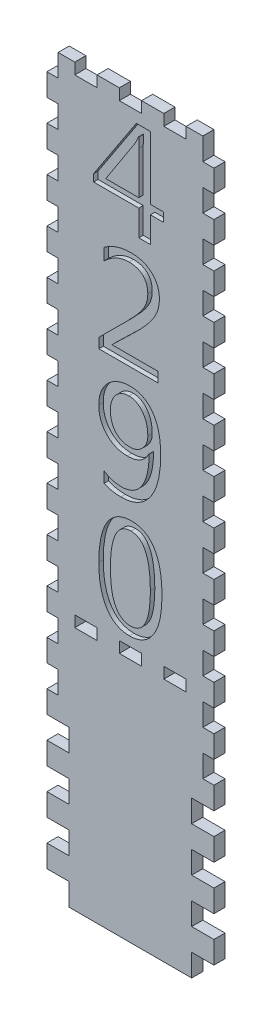
from build123d import *

# Parameters (mm, degrees)
SKETCH2_W           = 95.25
SKETCH2_H           = 419.1
BOSS_EXTRUDE1_DEPTH = 6.35
SKETCH3_W           = 6.35
SKETCH3_H           = 12.7
CUT_EXTRUDE1_DEPTH  = 7.35
LPATTERN1_COUNT     = 17
LPATTERN1_PITCH     = 25.4
SKETCH4_W           = 12.7
SKETCH4_H           = 6.35
CUT_EXTRUDE2_DEPTH  = 7.35
SKETCH5_W           = 6.35
SKETCH5_H           = 12.7
CUT_EXTRUDE3_DEPTH  = 7.35
LPATTERN2_COUNT     = 4
LPATTERN2_PITCH     = 25.4
SKETCH6_W           = 12.7
SKETCH6_H           = 6.35
CUT_EXTRUDE4_DEPTH  = 7.35
LPATTERN3_COUNT     = 2
LPATTERN3_PITCH     = 25.4
LPATTERN3_COL_COUNT = 2
LPATTERN3_COL_PITCH = 25.4
CUT_EXTRUDE5_DEPTH  = 2.54


with BuildPart() as part:
    # Sketch2 → Boss-Extrude1 (new body)
    with BuildSketch(Plane.XY):
        with Locations((47.625, 209.55)):
            Rectangle(SKETCH2_W, SKETCH2_H)
    extrude(amount=BOSS_EXTRUDE1_DEPTH)

    # Sketch3 → Cut-Extrude1 (cut, through all)
    with BuildSketch(Plane.XY.offset(6.35)):
        with Locations((3.175, 6.35)):
            Rectangle(SKETCH3_W, SKETCH3_H)
        with Locations((92.075, 6.35)):
            Rectangle(SKETCH3_W, SKETCH3_H)
    cut_extrude1 = extrude(amount=-CUT_EXTRUDE1_DEPTH, mode=Mode.SUBTRACT)

    # LPattern1: Cut-Extrude1 ×17
    with Locations(*[(0, i * LPATTERN1_PITCH, 0) for i in range(1, LPATTERN1_COUNT)]):
        add(cut_extrude1, mode=Mode.SUBTRACT)

    # Sketch4 → Cut-Extrude2 (cut, through all)
    with BuildSketch(Plane.XY.offset(6.35)):
        with Locations((47.625, 415.925)):
            Rectangle(SKETCH4_W, SKETCH4_H)
        with Locations((22.225, 415.925)):
            Rectangle(SKETCH4_W, SKETCH4_H)
        with Locations((73.025, 415.925)):
            Rectangle(SKETCH4_W, SKETCH4_H)
    extrude(amount=-CUT_EXTRUDE2_DEPTH, mode=Mode.SUBTRACT)

    # Sketch5 → Cut-Extrude3 (cut, through all)
    with BuildSketch(Plane.XY.offset(6.35)):
        with Locations((9.525, 6.35)):
            Rectangle(SKETCH5_W, SKETCH5_H)
        with Locations((85.725, 6.35)):
            Rectangle(SKETCH5_W, SKETCH5_H)
    cut_extrude3 = extrude(amount=-CUT_EXTRUDE3_DEPTH, mode=Mode.SUBTRACT)

    # LPattern2: Cut-Extrude3 ×4
    with Locations(*[(0, i * LPATTERN2_PITCH, 0) for i in range(1, LPATTERN2_COUNT)]):
        add(cut_extrude3, mode=Mode.SUBTRACT)

    # Sketch6 → Cut-Extrude4 (cut, through all)
    with BuildSketch(Plane.XY.offset(6.35)):
        with Locations((47.625, 142.875)):
            Rectangle(SKETCH6_W, SKETCH6_H)
    cut_extrude4 = extrude(amount=-CUT_EXTRUDE4_DEPTH, mode=Mode.SUBTRACT)

    # LPattern3: Cut-Extrude4 ×2
    with Locations(*[(i * LPATTERN3_PITCH, 0, 0) for i in range(1, LPATTERN3_COUNT)]):
        add(cut_extrude4, mode=Mode.SUBTRACT)

    # LPattern3 col: Cut-Extrude4 ×2
    with Locations(*[(-i * LPATTERN3_COL_PITCH, 0, 0) for i in range(1, LPATTERN3_COL_COUNT)]):
        add(cut_extrude4, mode=Mode.SUBTRACT)

    # Sketch7 → Cut-Extrude5 (cut)
    with BuildSketch(Plane.XY.offset(6.35)):
        Polygon((66.347473684, 365.225263158), (58.994842105, 365.225263158), (58.994842105, 350.52), (52.377473684, 350.52), (52.377473684, 365.225263158), (26.643263158, 365.225263158), (26.643263158, 369.361118421), (50.987366776, 406.4), (58.994842105, 406.4), (58.994842105, 370.372105263), (66.347473684, 370.372105263), align=None)
        with BuildLine():
            Line((52.377473684, 370.372105263), (52.377473684, 394.704720395))
            add(Edge.make_bspline(
                [(52.377473684, 394.704720395), (52.388280309, 395.620092385), (52.411121203, 397.554823508), (52.494422978, 399.487912378), (52.5383125, 400.50640625)],
                knots=[0, 0, 0, 0, 0.002746133, 0.005804229, 0.005804229, 0.005804229, 0.005804229], degree=3))
            Line((52.5383125, 400.50640625), (52.377473684, 400.50640625))
            add(Edge.make_bspline(
                [(52.377473684, 400.50640625), (52.268298001, 400.23754225), (52.024369803, 399.636826877), (51.566852144, 398.646813106), (50.970030559, 397.480008962), (50.525074381, 396.638044684), (50.286569079, 396.186735197)],
                knots=[0, 0, 0, 0, 0.000870476, 0.001944879, 0.003270444, 0.004801821, 0.004801821, 0.004801821, 0.004801821], degree=3))
            Line((50.286569079, 396.186735197), (33.54784375, 370.372105263))
            Line((33.54784375, 370.372105263), (52.377473684, 370.372105263))
        make_face(mode=Mode.SUBTRACT)
        with BuildLine():
            Line((63.406421053, 284.346315789), (29.584315789, 284.346315789))
            Line((29.584315789, 284.346315789), (29.584315789, 289.998651316))
            Line((29.584315789, 289.998651316), (45.920944079, 306.277837171))
            add(Edge.make_bspline(
                [(45.920944079, 306.277837171), (46.424180259, 306.781776596), (47.403956985, 307.762922505), (48.802074245, 309.214703689), (50.083014798, 310.611140989), (51.251077352, 311.943602605), (52.323826912, 313.198147905), (53.264671489, 314.400862364), (54.110599327, 315.523432912), (55.067027443, 316.929922001), (56.059985441, 318.682722154), (56.911097233, 320.877906643), (57.419517358, 323.150388241), (57.489331051, 324.69139001), (57.524315789, 325.463610197)],
                knots=[0, 0, 0, 0, 0.002136519, 0.0041597, 0.006046122, 0.007820712, 0.009475573, 0.010997092, 0.012400993, 0.013691493, 0.016098407, 0.018426066, 0.020731362, 0.023046969, 0.023046969, 0.023046969, 0.023046969], degree=3))
            add(Edge.make_bspline(
                [(57.524315789, 325.463610197), (57.514635558, 325.862149993), (57.495690632, 326.642121662), (57.37335109, 327.777250653), (57.151643335, 328.840992955), (56.856810686, 329.836501691), (56.464816334, 330.762107925), (55.978947694, 331.615158354), (55.413223909, 332.401273896), (54.768993183, 333.117412387), (54.039830798, 333.753755675), (53.231194025, 334.303309313), (52.353349238, 334.782423002), (51.393154072, 335.154728995), (50.368207585, 335.458082751), (49.266601956, 335.659146269), (48.095317636, 335.787752189), (47.288431348, 335.805587237), (46.874488487, 335.814736842)],
                knots=[0, 0, 0, 0, 0.001195686, 0.002340045, 0.003419291, 0.004451466, 0.005450106, 0.00642764, 0.007390551, 0.008350372, 0.009311156, 0.010286257, 0.011278333, 0.012304481, 0.013369694, 0.014480518, 0.015659138, 0.016900745, 0.016900745, 0.016900745, 0.016900745], degree=3))
            add(Edge.make_bspline(
                [(46.874488487, 335.814736842), (46.25286361, 335.79464315), (45.005788435, 335.75433211), (43.151945351, 335.432571391), (41.319800132, 334.910310756), (39.508805702, 334.178091001), (37.713595454, 333.247243103), (35.949789473, 332.092774033), (34.195710705, 330.751210173), (33.09149022, 329.724005205), (32.525368421, 329.197368421)],
                knots=[0, 0, 0, 0, 0.001864005, 0.00373948, 0.005626847, 0.007570338, 0.009589731, 0.011683348, 0.013887013, 0.016205439, 0.016205439, 0.016205439, 0.016205439], degree=3))
            Line((32.525368421, 329.197368421), (32.525368421, 335.872179276))
            add(Edge.make_bspline(
                [(32.525368421, 335.872179276), (33.081392691, 336.280781464), (34.185531177, 337.092173026), (35.952907748, 338.119204914), (37.777449228, 339.005833765), (39.677783191, 339.708952614), (41.639874019, 340.286883805), (43.677191261, 340.662705656), (45.776598564, 340.918351154), (47.199206981, 340.947042896), (47.919940789, 340.961578947)],
                knots=[0, 0, 0, 0, 0.002068725, 0.004108021, 0.006122277, 0.008147284, 0.010179837, 0.012250476, 0.014355253, 0.016516585, 0.016516585, 0.016516585, 0.016516585], degree=3))
            add(Edge.make_bspline(
                [(47.919940789, 340.961578947), (48.533340814, 340.953587419), (49.729010038, 340.938009943), (51.470941529, 340.728696975), (53.120401315, 340.433474499), (54.662404553, 339.976331525), (56.112970377, 339.421327851), (57.447087516, 338.711885893), (58.692614943, 337.89265137), (59.824127913, 336.942349453), (60.834571124, 335.881587928), (61.72598193, 334.742308658), (62.480063224, 333.514097248), (63.091123142, 332.195217168), (63.562169027, 330.788192145), (63.890647629, 329.2936227), (64.104976112, 327.717709362), (64.129277518, 326.636157461), (64.141684211, 326.083988487)],
                knots=[0, 0, 0, 0, 0.001839055, 0.003584776, 0.005256657, 0.00685999, 0.008402445, 0.009908139, 0.011383414, 0.012867609, 0.014330216, 0.015771094, 0.017199598, 0.018643907, 0.020122534, 0.021641536, 0.023228986, 0.024884763, 0.024884763, 0.024884763, 0.024884763], degree=3))
            add(Edge.make_bspline(
                [(64.141684211, 326.083988487), (64.132428295, 325.639483869), (64.113872596, 324.748367965), (63.976184445, 323.414687035), (63.726945853, 322.093411946), (63.410558875, 320.773553), (62.979788994, 319.467290717), (62.466493615, 318.162491649), (61.834268288, 316.878490523), (61.134460559, 315.572547227), (60.286394085, 314.248619886), (59.30784552, 312.858154214), (58.178086715, 311.388859647), (56.903533298, 309.839799938), (55.473594387, 308.21590248), (53.885244676, 306.524698203), (52.166776858, 304.738642787), (50.948525035, 303.547971807), (50.321034539, 302.9346875)],
                knots=[0, 0, 0, 0, 0.001333457, 0.002673233, 0.004016256, 0.005364869, 0.006741811, 0.008139163, 0.009567621, 0.011032797, 0.012581827, 0.014280648, 0.016132683, 0.018140573, 0.020297749, 0.022622515, 0.025100542, 0.027732634, 0.027732634, 0.027732634, 0.027732634], degree=3))
            Line((50.321034539, 302.9346875), (37.224159539, 290.228421053))
            Line((37.224159539, 290.228421053), (37.224159539, 290.079070724))
            Line((37.224159539, 290.079070724), (63.406421053, 290.079070724))
            Line((63.406421053, 290.079070724), (63.406421053, 284.346315789))
        make_face()
        with BuildLine():
            Line((32.525368421, 219.321480263), (32.525368421, 225.525263158))
            add(Edge.make_bspline(
                [(32.525368421, 225.525263158), (32.912936327, 225.29008708), (33.678389294, 224.825610471), (34.866453366, 224.230549391), (36.068817976, 223.716345854), (37.292372091, 223.309192909), (38.530987956, 222.981113547), (39.783313171, 222.754228425), (41.05410218, 222.61002138), (41.907246616, 222.592850605), (42.336536184, 222.584210526)],
                knots=[0, 0, 0, 0, 0.00135953, 0.002685095, 0.003982429, 0.005279408, 0.006550067, 0.007823218, 0.009094449, 0.01038198, 0.01038198, 0.01038198, 0.01038198], degree=3))
            add(Edge.make_bspline(
                [(42.336536184, 222.584210526), (42.946840108, 222.598946099), (44.144526951, 222.627863823), (45.882181555, 222.940613636), (47.524655753, 223.414924585), (49.048920459, 224.116651516), (50.476758173, 224.994819317), (51.79948828, 226.075064369), (53.003390312, 227.36206971), (54.110582692, 228.828014014), (55.094984841, 230.472709594), (55.950028018, 232.288915017), (56.648828462, 234.272485624), (57.255082891, 236.406860682), (57.708820054, 238.712565964), (58.021142036, 241.180934387), (58.221038608, 243.811666713), (58.246472616, 245.618248963), (58.259578947, 246.549194079)],
                knots=[0, 0, 0, 0, 0.00182898, 0.00358927, 0.005279483, 0.006945274, 0.008606344, 0.010296558, 0.01205193, 0.01388091, 0.015797973, 0.017791979, 0.019892456, 0.022100189, 0.02444339, 0.026934273, 0.029560919, 0.032353472, 0.032353472, 0.032353472, 0.032353472], degree=3))
            add(Edge.make_bspline(
                [(58.259578947, 246.549194079), (58.2327466, 246.543138734), (58.182832194, 246.531874385), (58.133186442, 246.543717455), (58.110228618, 246.549194079)],
                knots=[0, 0, 0, 0, 8.1236e-05, 0.000151118, 0.000151118, 0.000151118, 0.000151118], degree=3))
            add(Edge.make_bspline(
                [(58.110228618, 246.549194079), (57.804701544, 245.987492974), (57.206941762, 244.888532005), (56.053306012, 243.443275545), (54.741629714, 242.217729519), (53.260874947, 241.222266521), (51.624592639, 240.428493463), (49.814001076, 239.882788036), (47.843315767, 239.561468208), (46.477466043, 239.517820388), (45.77159375, 239.495263158)],
                knots=[0, 0, 0, 0, 0.001915238, 0.003747138, 0.005519272, 0.007281361, 0.009079777, 0.0109549, 0.012934257, 0.015051258, 0.015051258, 0.015051258, 0.015051258], degree=3))
            add(Edge.make_bspline(
                [(45.77159375, 239.495263158), (45.192405325, 239.505632938), (44.056016077, 239.525978834), (42.396333729, 239.770661183), (40.809670362, 240.126584475), (39.312631323, 240.665252894), (37.887576693, 241.329674648), (36.547392936, 242.156366028), (35.278357211, 243.119248715), (34.114581442, 244.238569835), (33.044898229, 245.456436135), (32.121934878, 246.78915868), (31.340217275, 248.20704629), (30.691575304, 249.705674722), (30.197631483, 251.293443032), (29.846027329, 252.962755584), (29.618227914, 254.718900922), (29.595785295, 255.919243224), (29.584315789, 256.532689145)],
                knots=[0, 0, 0, 0, 0.00173613, 0.003406353, 0.00502264, 0.006606885, 0.008169193, 0.009731669, 0.011321736, 0.01293884, 0.014567533, 0.016176946, 0.0177916, 0.019417779, 0.021067407, 0.022770883, 0.024530723, 0.026370173, 0.026370173, 0.026370173, 0.026370173], degree=3))
            add(Edge.make_bspline(
                [(29.584315789, 256.532689145), (29.600375888, 257.184335692), (29.631937134, 258.464949062), (29.861617632, 260.338800498), (30.253855131, 262.123737199), (30.803813016, 263.818992286), (31.521181877, 265.422041193), (32.388737239, 266.939756553), (33.411194923, 268.365828642), (34.587533996, 269.683513275), (35.870523495, 270.888619385), (37.274244162, 271.922883666), (38.750262088, 272.817432437), (40.320385368, 273.547436701), (41.985533271, 274.092277085), (43.729880254, 274.498337261), (45.565477077, 274.743900474), (46.820120703, 274.773029407), (47.460401316, 274.787894737)],
                knots=[0, 0, 0, 0, 0.001954698, 0.003841365, 0.005653198, 0.007429758, 0.009178312, 0.010912502, 0.012666031, 0.01443201, 0.016204144, 0.017936621, 0.019652718, 0.02137465, 0.02311848, 0.024899233, 0.026741765, 0.028662027, 0.028662027, 0.028662027, 0.028662027], degree=3))
            add(Edge.make_bspline(
                [(47.460401316, 274.787894737), (48.127912342, 274.768173716), (49.431578674, 274.729658052), (51.332659893, 274.42429614), (53.122665565, 273.925701518), (54.792779881, 273.199345934), (56.356982153, 272.294122164), (57.793392304, 271.159736953), (59.117633164, 269.83159825), (60.327238032, 268.305528756), (61.409192721, 266.589486011), (62.33628842, 264.678686722), (63.131217748, 262.592066789), (63.768214418, 260.314059832), (64.272112041, 257.85720303), (64.619370885, 255.211861634), (64.843521788, 252.389236889), (64.865597758, 250.444244547), (64.876947368, 249.444292763)],
                knots=[0, 0, 0, 0, 0.002001669, 0.003909311, 0.005760384, 0.00756155, 0.009358535, 0.011167196, 0.013035621, 0.014973365, 0.016997329, 0.019109024, 0.021334412, 0.023687309, 0.026197274, 0.028852134, 0.031686719, 0.034686006, 0.034686006, 0.034686006, 0.034686006], degree=3))
            add(Edge.make_bspline(
                [(64.876947368, 249.444292763), (64.861802976, 248.199049441), (64.832356379, 245.777811463), (64.533481599, 242.261288844), (64.088211472, 238.962336071), (63.43558059, 235.880911486), (62.585662748, 233.020785211), (61.572939263, 230.370484241), (60.34373022, 227.954506151), (58.949486364, 225.752769775), (57.374279726, 223.797591852), (55.655046202, 222.0877636), (53.776052141, 220.651670751), (51.75544253, 219.470424633), (49.583434361, 218.557419668), (47.26974228, 217.902277135), (44.805101643, 217.502873378), (43.111621088, 217.459548822), (42.244628289, 217.437368421)],
                knots=[0, 0, 0, 0, 0.003734889, 0.007262079, 0.010579766, 0.013716313, 0.016700601, 0.01952317, 0.022215425, 0.024819159, 0.027327466, 0.029732103, 0.032075867, 0.034402931, 0.036735122, 0.039124313, 0.04160234, 0.044201812, 0.044201812, 0.044201812, 0.044201812], degree=3))
            add(Edge.make_bspline(
                [(42.244628289, 217.437368421), (41.343255123, 217.456701793), (39.590477559, 217.494296768), (37.059435016, 217.862629547), (34.69454084, 218.426078778), (33.238981842, 219.026911463), (32.525368421, 219.321480263)],
                knots=[0, 0, 0, 0, 0.002702238, 0.005254673, 0.00765931, 0.009972122, 0.009972122, 0.009972122, 0.009972122], degree=3))
        make_face()
        with BuildLine():
            add(Edge.make_bspline(
                [(46.679184211, 269.641052632), (46.310968442, 269.62958205), (45.59008635, 269.607125279), (44.529792041, 269.442728), (43.52066024, 269.167682214), (42.552665786, 268.783649856), (41.635200172, 268.29014852), (40.762959658, 267.682154237), (39.938018377, 266.971202533), (39.168297814, 266.154648762), (38.479174117, 265.25360251), (37.856190022, 264.296643248), (37.359411967, 263.263831312), (36.924369382, 262.185637076), (36.612051257, 261.038357299), (36.36239475, 259.839062363), (36.228523506, 258.576862629), (36.210720889, 257.71627728), (36.201684211, 257.279440789)],
                knots=[0, 0, 0, 0, 0.00110439, 0.002162142, 0.003210053, 0.004236201, 0.005279631, 0.006328109, 0.007419697, 0.008541222, 0.009687886, 0.010819254, 0.011959859, 0.013120424, 0.014302399, 0.015521316, 0.016792547, 0.01810304, 0.01810304, 0.01810304, 0.01810304], degree=3))
            add(Edge.make_bspline(
                [(36.201684211, 257.279440789), (36.20999761, 256.800399367), (36.226195299, 255.867043034), (36.366586465, 254.507574578), (36.592845366, 253.22750628), (36.916801579, 252.024726646), (37.324431864, 250.898341718), (37.837663118, 249.85382357), (38.43359303, 248.884596172), (39.124351527, 247.999651295), (39.889072997, 247.207433923), (40.729577816, 246.523529575), (41.624448454, 245.929866838), (42.597723306, 245.462000413), (43.629043223, 245.090668897), (44.726144865, 244.824528708), (45.890279725, 244.679943045), (46.686471439, 244.654889923), (47.092769737, 244.642105263)],
                knots=[0, 0, 0, 0, 0.001436796, 0.002799429, 0.004095186, 0.005332534, 0.006531967, 0.007682882, 0.008817861, 0.009939328, 0.011044255, 0.012113672, 0.013184323, 0.014258173, 0.015344732, 0.016467669, 0.017637578, 0.018856712, 0.018856712, 0.018856712, 0.018856712], degree=3))
            add(Edge.make_bspline(
                [(47.092769737, 244.642105263), (47.449480176, 244.649704011), (48.154654706, 244.664725842), (49.189217154, 244.821013863), (50.182133648, 245.060624162), (51.134949596, 245.395418778), (52.041943028, 245.834342447), (52.908055464, 246.36528362), (53.731246072, 246.992967521), (54.503444708, 247.709686543), (55.207093538, 248.496870326), (55.841060671, 249.325760084), (56.352246769, 250.215389653), (56.781161725, 251.137413346), (57.118869083, 252.102597037), (57.358966736, 253.110740176), (57.498612114, 254.165953222), (57.51564773, 254.881761262), (57.524315789, 255.245978618)],
                knots=[0, 0, 0, 0, 0.001069417, 0.002114112, 0.003131151, 0.004130385, 0.005137513, 0.006148304, 0.007173101, 0.008238065, 0.009303773, 0.010337737, 0.01136234, 0.012374958, 0.01338503, 0.014424405, 0.015478908, 0.016571281, 0.016571281, 0.016571281, 0.016571281], degree=3))
            add(Edge.make_bspline(
                [(57.524315789, 255.245978618), (57.515590114, 255.763236242), (57.498494246, 256.776678433), (57.361620172, 258.263337031), (57.120044386, 259.675923754), (56.789439515, 261.013715491), (56.359355973, 262.276679381), (55.846114029, 263.470359697), (55.237843783, 264.59461383), (54.521968803, 265.621369477), (53.750181552, 266.563490831), (52.908231716, 267.387307053), (52.004311939, 268.076058381), (51.059004995, 268.666809235), (50.040596132, 269.098933537), (48.968354698, 269.409937265), (47.843526257, 269.615097066), (47.070696096, 269.632325031), (46.679184211, 269.641052632)],
                knots=[0, 0, 0, 0, 0.001551626, 0.00304004, 0.004473571, 0.00584725, 0.007169674, 0.008471528, 0.009741408, 0.010996969, 0.012220803, 0.013390713, 0.014521264, 0.015624637, 0.016725855, 0.017827373, 0.018970059, 0.020143291, 0.020143291, 0.020143291, 0.020143291], degree=3))
        make_face(mode=Mode.SUBTRACT)
        with BuildLine():
            add(Edge.make_bspline(
                [(47.023838816, 151.263684211), (46.356005098, 151.285332682), (45.050006657, 151.327667875), (43.147679081, 151.672062109), (41.35725295, 152.218259372), (39.679017461, 152.999072431), (38.120255616, 154.007308627), (36.674354213, 155.237316475), (35.347935423, 156.687351278), (34.139052712, 158.352244276), (33.061403958, 160.227667006), (32.134104782, 162.309648241), (31.343907394, 164.581908116), (30.690601367, 167.047056472), (30.187683718, 169.711887474), (29.843507875, 172.571390094), (29.616912136, 175.627112264), (29.595408307, 177.72889415), (29.584315789, 178.813075658)],
                knots=[0, 0, 0, 0, 0.002002295, 0.003915637, 0.005779784, 0.007604429, 0.009449538, 0.011332424, 0.013283776, 0.01533121, 0.017492909, 0.019760569, 0.02215861, 0.024702862, 0.027404416, 0.030287133, 0.033339398, 0.03659137, 0.03659137, 0.03659137, 0.03659137], degree=3))
            add(Edge.make_bspline(
                [(29.584315789, 178.813075658), (29.601056036, 180.000522971), (29.633539962, 182.304727315), (29.846065696, 185.649405128), (30.222202445, 188.771904029), (30.750704962, 191.671554868), (31.403583291, 194.357320671), (32.230926575, 196.813182968), (33.206542895, 199.046185296), (34.33191519, 201.053186967), (35.594533673, 202.836972578), (37.006993601, 204.381412781), (38.556378032, 205.689340774), (40.233300859, 206.769234413), (42.049294966, 207.609850883), (44.004736075, 208.185469777), (46.086918994, 208.555989545), (47.520042049, 208.594507824), (48.253106908, 208.614210526)],
                knots=[0, 0, 0, 0, 0.003562339, 0.006912607, 0.010048985, 0.012991922, 0.015750427, 0.018333497, 0.020756288, 0.023050537, 0.025224746, 0.027298187, 0.029311952, 0.031290975, 0.033264856, 0.035292892, 0.037391263, 0.039588569, 0.039588569, 0.039588569, 0.039588569], degree=3))
            add(Edge.make_bspline(
                [(48.253106908, 208.614210526), (48.955387579, 208.592867971), (50.322276199, 208.551327748), (52.304514945, 208.207450822), (54.156677021, 207.666621383), (55.865100095, 206.870131439), (57.440448645, 205.865298666), (58.880244593, 204.633197164), (60.170947171, 203.170697136), (61.321314642, 201.487308706), (62.34714995, 199.590442907), (63.229920094, 197.469194318), (63.952814924, 195.117895665), (64.578409216, 192.557707186), (65.039309241, 189.768828769), (65.364130166, 186.765465298), (65.577005405, 183.541716115), (65.600215894, 181.317921606), (65.612210526, 180.168717105)],
                knots=[0, 0, 0, 0, 0.00210553, 0.004098112, 0.006017205, 0.00787795, 0.009732727, 0.011606865, 0.01354362, 0.015567193, 0.017710866, 0.02000238, 0.022447701, 0.025083676, 0.027903509, 0.030920457, 0.034143873, 0.037591108, 0.037591108, 0.037591108, 0.037591108], degree=3))
            add(Edge.make_bspline(
                [(65.612210526, 180.168717105), (65.596857991, 179.030937292), (65.566998836, 176.81806879), (65.334385396, 173.604582472), (64.965398586, 170.595165692), (64.425476312, 167.797521183), (63.743050989, 165.207093471), (62.904541937, 162.821589079), (61.909462377, 160.645652373), (60.759203184, 158.681412354), (59.471452448, 156.941301928), (58.064478217, 155.417821771), (56.524774627, 154.130687084), (54.862005296, 153.07452601), (53.068125753, 152.266595768), (51.163745518, 151.676628561), (49.131452571, 151.326092986), (47.737507984, 151.284816744), (47.023838816, 151.263684211)],
                knots=[0, 0, 0, 0, 0.003413028, 0.006638, 0.009660367, 0.012503809, 0.015179048, 0.01768988, 0.020080203, 0.022346087, 0.024505953, 0.026562521, 0.028552717, 0.030509709, 0.032453132, 0.034437217, 0.03647703, 0.038616975, 0.038616975, 0.038616975, 0.038616975], degree=3))
        make_face()
        with BuildLine():
            add(Edge.make_bspline(
                [(47.908452303, 203.467368421), (47.435879533, 203.451421335), (46.508356758, 203.420121848), (45.16782451, 203.123839038), (43.915086197, 202.647832932), (42.754712428, 201.977544114), (41.701732615, 201.095064131), (40.732122623, 200.041479086), (39.852459374, 198.800455997), (39.088839331, 197.35762456), (38.402397496, 195.735335836), (37.803263829, 193.922806733), (37.322633396, 191.917830206), (36.906082667, 189.729470865), (36.590119901, 187.347440551), (36.365017661, 184.775345153), (36.225910538, 182.016068827), (36.209928506, 180.115273983), (36.201684211, 179.134753289)],
                knots=[0, 0, 0, 0, 0.00141607, 0.002779332, 0.004095755, 0.005423855, 0.00677862, 0.008201385, 0.00970918, 0.011328405, 0.013088845, 0.014988896, 0.017048029, 0.019269678, 0.021669452, 0.02425311, 0.027013791, 0.029955203, 0.029955203, 0.029955203, 0.029955203], degree=3))
            add(Edge.make_bspline(
                [(36.201684211, 179.134753289), (36.209608411, 178.215473089), (36.224938109, 176.437087049), (36.367514665, 173.862061462), (36.58007432, 171.465959751), (36.880962624, 169.243062941), (37.301674888, 167.202406286), (37.771323598, 165.326870938), (38.355255132, 163.635220088), (39.034835364, 162.121655162), (39.790575697, 160.775901063), (40.640372103, 159.6052291), (41.587797044, 158.614037629), (42.633811412, 157.814773635), (43.76479383, 157.180012559), (44.990156547, 156.73326583), (46.307435812, 156.462421806), (47.214003823, 156.428112305), (47.678682566, 156.410526316)],
                knots=[0, 0, 0, 0, 0.00275762, 0.005334731, 0.007734285, 0.009973155, 0.01205951, 0.013982176, 0.015769734, 0.017420322, 0.018953594, 0.020392043, 0.021748901, 0.023051768, 0.024327197, 0.025624786, 0.026949603, 0.028342745, 0.028342745, 0.028342745, 0.028342745], degree=3))
            add(Edge.make_bspline(
                [(47.678682566, 156.410526316), (48.135541313, 156.42875103), (49.030369127, 156.464446923), (50.332491337, 156.728143226), (51.538427441, 157.19614204), (52.65425963, 157.834836971), (53.682660764, 158.654058558), (54.611094734, 159.662752822), (55.45280668, 160.851066634), (56.214546884, 162.211480913), (56.858543834, 163.763167632), (57.432478135, 165.483395135), (57.928542138, 167.381656973), (58.30657627, 169.464923064), (58.615421524, 171.722709052), (58.847616814, 174.159875719), (58.966346983, 176.782239315), (58.985134657, 178.590860826), (58.994842105, 179.525361842)],
                knots=[0, 0, 0, 0, 0.001370216, 0.002683777, 0.003963906, 0.005234982, 0.006526811, 0.007892443, 0.009333459, 0.010886743, 0.012559689, 0.014365283, 0.016324196, 0.018439982, 0.02071299, 0.023159363, 0.025781785, 0.028585352, 0.028585352, 0.028585352, 0.028585352], degree=3))
            add(Edge.make_bspline(
                [(58.994842105, 179.525361842), (58.98540012, 180.490513565), (58.967107155, 182.36040487), (58.844451132, 185.073975703), (58.625261939, 187.602964087), (58.33501125, 189.946854499), (57.947360195, 192.103333811), (57.465906709, 194.071251651), (56.90909079, 195.8549522), (56.268664485, 197.454193276), (55.534474597, 198.866245892), (54.709899897, 200.092560273), (53.790859557, 201.132735904), (52.790493851, 201.991624676), (51.694862461, 202.663581379), (50.504909928, 203.116412589), (49.237352819, 203.422717279), (48.358379916, 203.452250824), (47.908452303, 203.467368421)],
                knots=[0, 0, 0, 0, 0.002895463, 0.00560969, 0.008146565, 0.010509175, 0.012692743, 0.014715663, 0.01658324, 0.018294215, 0.01987696, 0.021349101, 0.022716279, 0.024028433, 0.025291383, 0.026550093, 0.027834854, 0.029182145, 0.029182145, 0.029182145, 0.029182145], degree=3))
        make_face(mode=Mode.SUBTRACT)
    extrude(amount=-CUT_EXTRUDE5_DEPTH, mode=Mode.SUBTRACT)


solid = part.part
